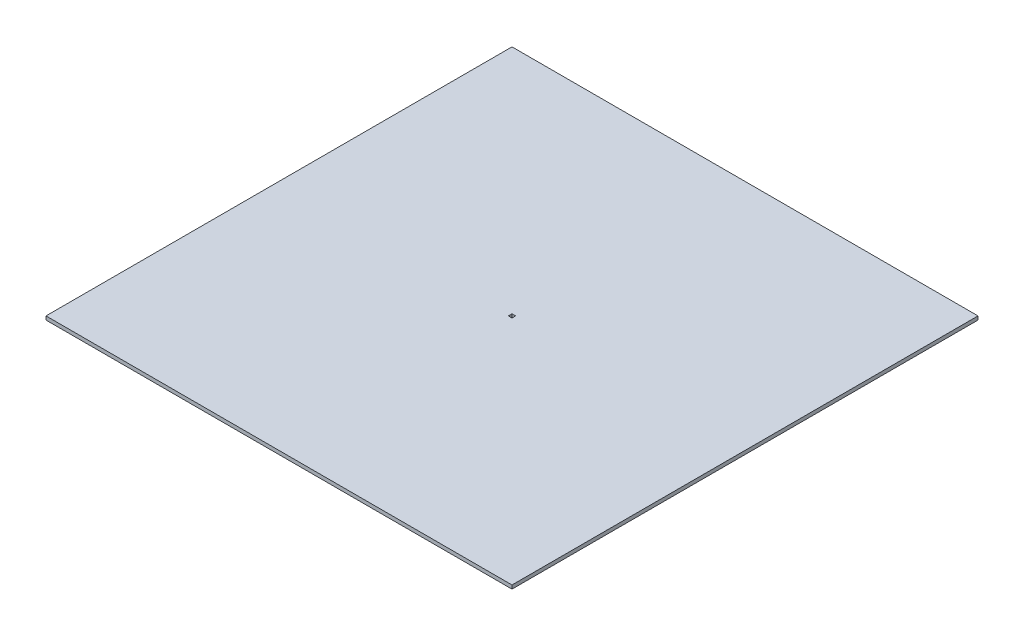
from build123d import *

# Parameters (mm, degrees)
SKETCH_1_W      = 1280
SKETCH_1_H      = 1280
SKETCH_1_W_2    = 10
SKETCH_1_H_2    = 10
EXTRUDE_1_DEPTH = 10


with BuildPart() as part:
    # 草图1 → 凸台-拉伸1 (new body)
    with BuildSketch(Plane(origin=(0, 0, 0), x_dir=(1, 0, 0), z_dir=(0, 1, 0))):
        Rectangle(SKETCH_1_W, SKETCH_1_H)
        Rectangle(SKETCH_1_W_2, SKETCH_1_H_2, mode=Mode.SUBTRACT)
    extrude(amount=EXTRUDE_1_DEPTH)


solid = part.part
